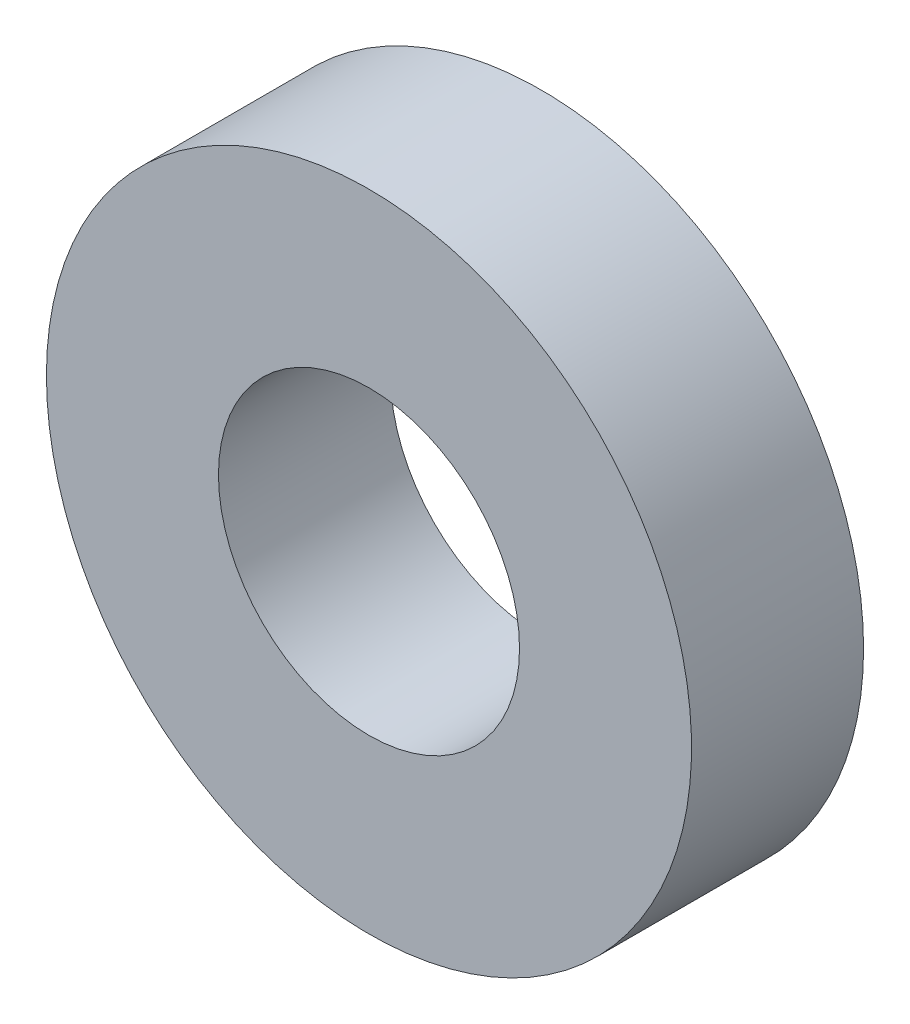
from build123d import *

# Parameters (mm, degrees)
SKETCH_1_R      = 11.25
SKETCH_1_R_2    = 5.25
EXTRUDE_1_DEPTH = 6


with BuildPart() as part:
    # Эскиз1 → Бобышка-Вытянуть1 (new body)
    with BuildSketch(Plane.XY):
        with Locations((0, 5.8)):
            Circle(SKETCH_1_R)
        with Locations((0, 5.8)):
            Circle(SKETCH_1_R_2, mode=Mode.SUBTRACT)
    extrude(amount=EXTRUDE_1_DEPTH)


solid = part.part
